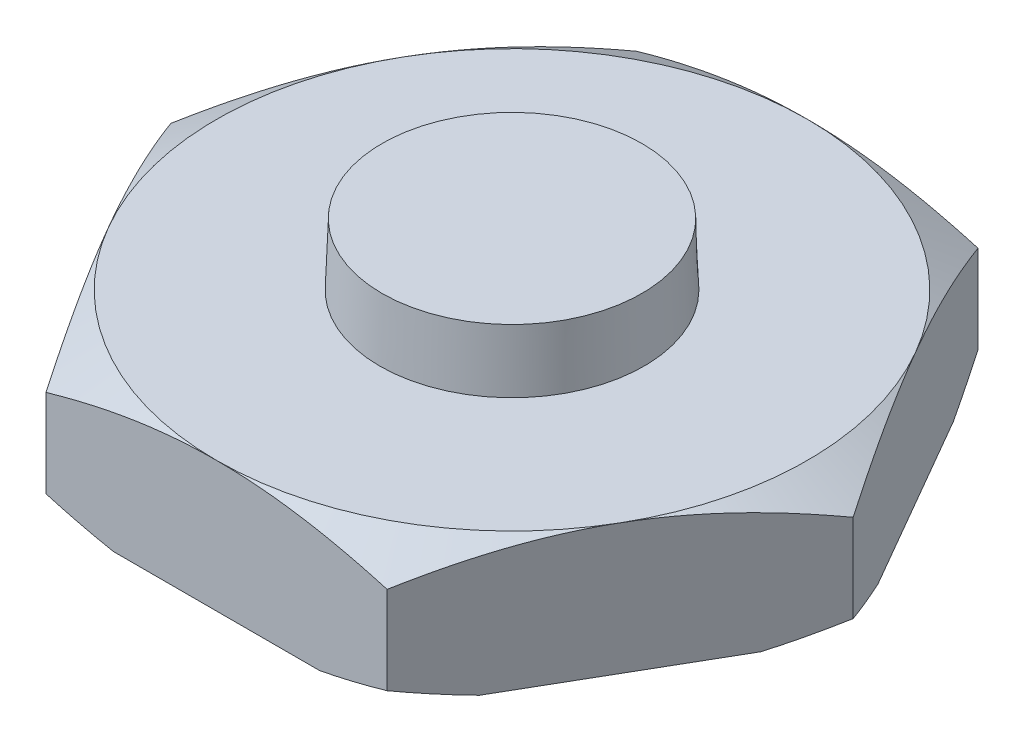
from build123d import *

# Parameters (mm, degrees)
SKETCH2_W          = 47.16496854
SKETCH2_H          = 39.085316542
CUT_EXTRUDE1_DEPTH = 5.61
SKETCH3_W          = 40
SKETCH3_H          = 40
CUT_EXTRUDE2_DEPTH = 50


with BuildPart() as part:
    # Sketch1 → Revolve1 (revolve)
    with BuildSketch(Plane.XY):
        Polygon((0, 34.0386), (5.5795, 34.0386), (5.5795, 14.2396), (5.682246885, 11.4036), (12.7, 11.4036), (17.933402515, 8.382093649), (13.45, 5.7936), (0, 5.7936), align=None)
    revolve(axis=Axis((0, 5.7936, 0), (0, 1, 0)))

    # Sketch2 → Cut-Extrude1 (cut)
    with BuildSketch(Plane(origin=(0, 11.4036, 0), x_dir=(1, 0, 0), z_dir=(0, 1, 0))):
        with Locations((0.151493475, -0.8079652)):
            Rectangle(SKETCH2_W, SKETCH2_H)
        Polygon((14.664696837, 0), (7.332348419, 12.7), (-7.332348419, 12.7), (-14.664696837, 0), (-7.332348419, -12.7), (7.332348419, -12.7), align=None, mode=Mode.SUBTRACT)
    extrude(amount=-CUT_EXTRUDE1_DEPTH, mode=Mode.SUBTRACT)

    # Sketch3 → Cut-Extrude2 (cut)
    with BuildSketch(Plane(origin=(0, 14.0616, 0), x_dir=(1, 0, 0), z_dir=(0, 1, 0))):
        Rectangle(SKETCH3_W, SKETCH3_H)
    extrude(amount=CUT_EXTRUDE2_DEPTH, mode=Mode.SUBTRACT)


solid = part.part
